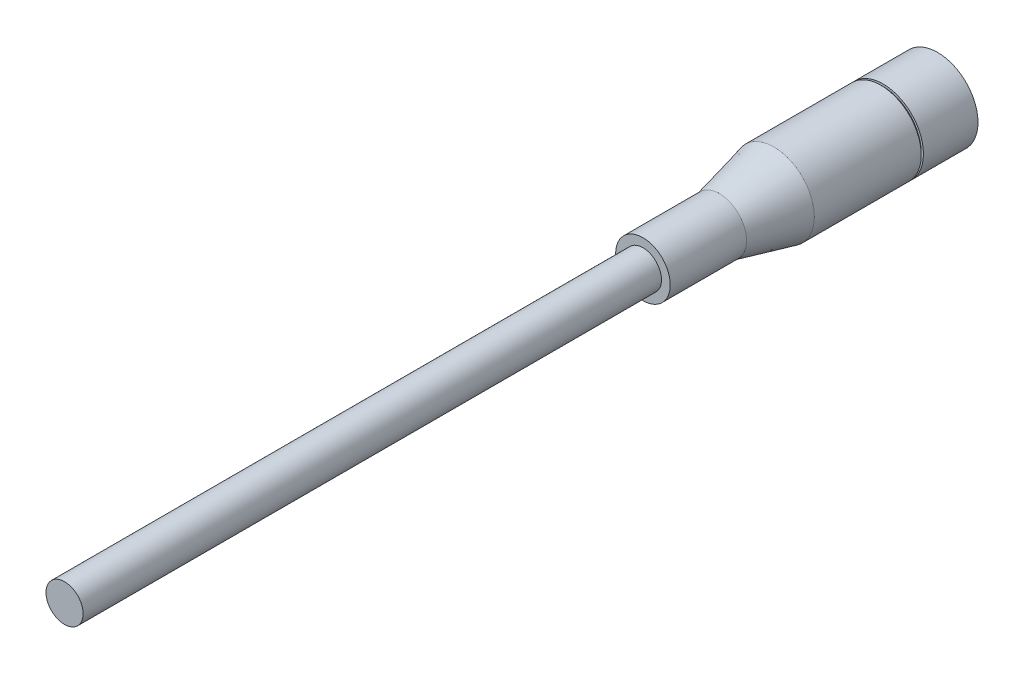
from build123d import *

# Parameters (mm, degrees)
SKETCH2_R          = 2.159
EXTRUDE1_DEPTH     = 101.6
SKETCH4_R          = 3.937
SKETCH4_R_2        = 3.175
SKETCH4_R_3        = 0.381
CUT_EXTRUDE2_DEPTH = 5.08


with BuildPart() as part:
    # S2D0001 → Revolve1 (revolve)
    with BuildSketch(Plane(origin=(0, 0, 0), x_dir=(0, 0, -1), z_dir=(1, 0, 0)), mode=Mode.PRIVATE) as revolve1_sk:
        Polygon((0, 0), (0, 4.699), (-6.35, 4.699), (-6.35, 4.445), (-6.604, 4.445), (-6.604, 4.699), (-19.05, 4.699), (-25.4, 3.175), (-34.29, 3.175), (-34.29, 0), align=None)
    revolve(revolve1_sk.sketch.rotate(Axis((0, 0, 36.0045), (0, 0, -1)), 90), axis=Axis((0, 0, 36.0045), (0, 0, -1)))  # turned: the seam where the file's is

    # Sketch2 → Extrude1 (add)
    with BuildSketch(Plane(origin=(0, 0, 0), x_dir=(-1, 0, 0), z_dir=(0, 0, -1))):
        Circle(SKETCH2_R)
    extrude(amount=-EXTRUDE1_DEPTH)

    # Sketch4 → Cut-Extrude2 (cut)
    with BuildSketch(Plane(origin=(0, 0, 0), x_dir=(-1, 0, 0), z_dir=(0, 0, -1))):
        Circle(SKETCH4_R)
        with Locations(Location((0, 0, 0), (0, 0, 180))):  # turned: the seam where the file's is
            Circle(SKETCH4_R_2, mode=Mode.SUBTRACT)
        with Locations((0, 2.54)):
            Circle(SKETCH4_R_3)
        with Locations((2.54, 0)):
            Circle(SKETCH4_R_3)
        with Locations((-2.54, 0)):
            Circle(SKETCH4_R_3)
    extrude(amount=-CUT_EXTRUDE2_DEPTH, mode=Mode.SUBTRACT)


solid = part.part
